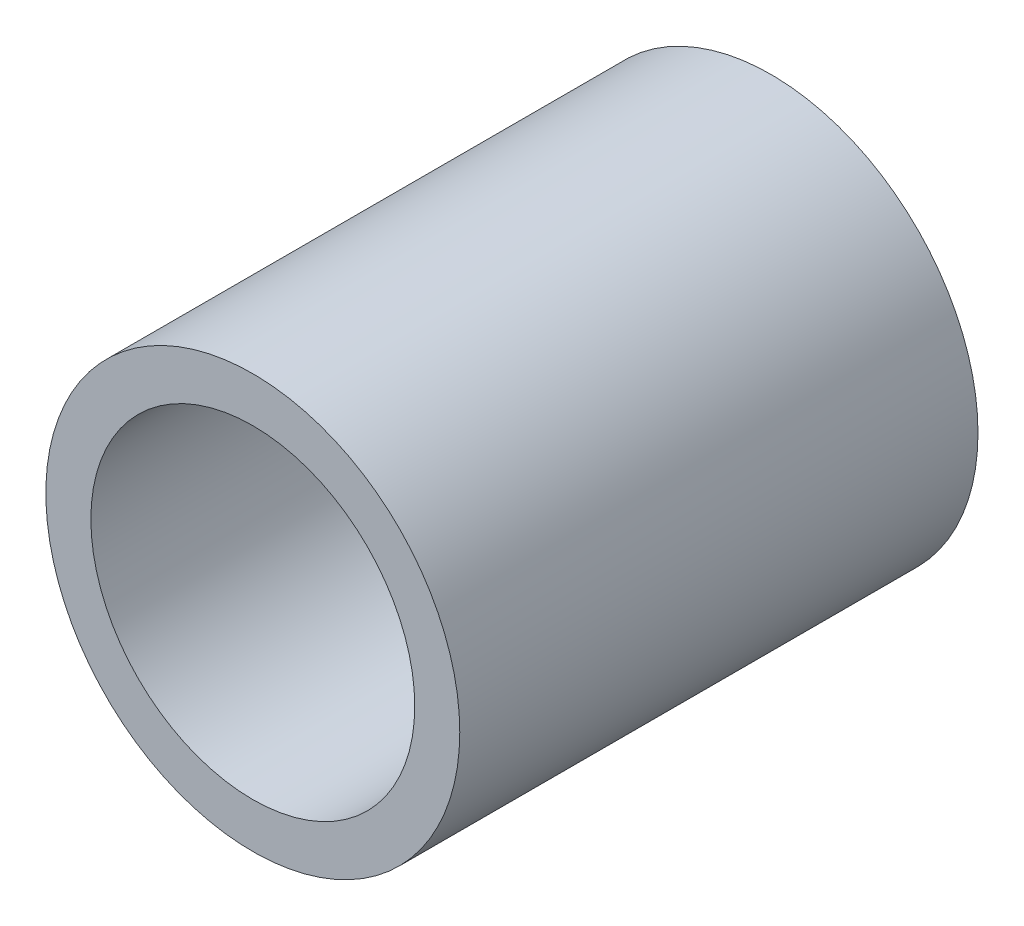
from build123d import *

# Parameters (mm, degrees)
SKETCH1_R           = 15.975
SKETCH1_R_2         = 12.5
BOSS_EXTRUDE1_DEPTH = 40


with BuildPart() as part:
    # Sketch1 → Boss-Extrude1 (new body)
    with BuildSketch(Plane.XY):
        with Locations((-7.473500512, 0)):
            Circle(SKETCH1_R)
        with Locations((-7.473500512, 0)):
            Circle(SKETCH1_R_2, mode=Mode.SUBTRACT)
    extrude(amount=BOSS_EXTRUDE1_DEPTH)


solid = part.part
